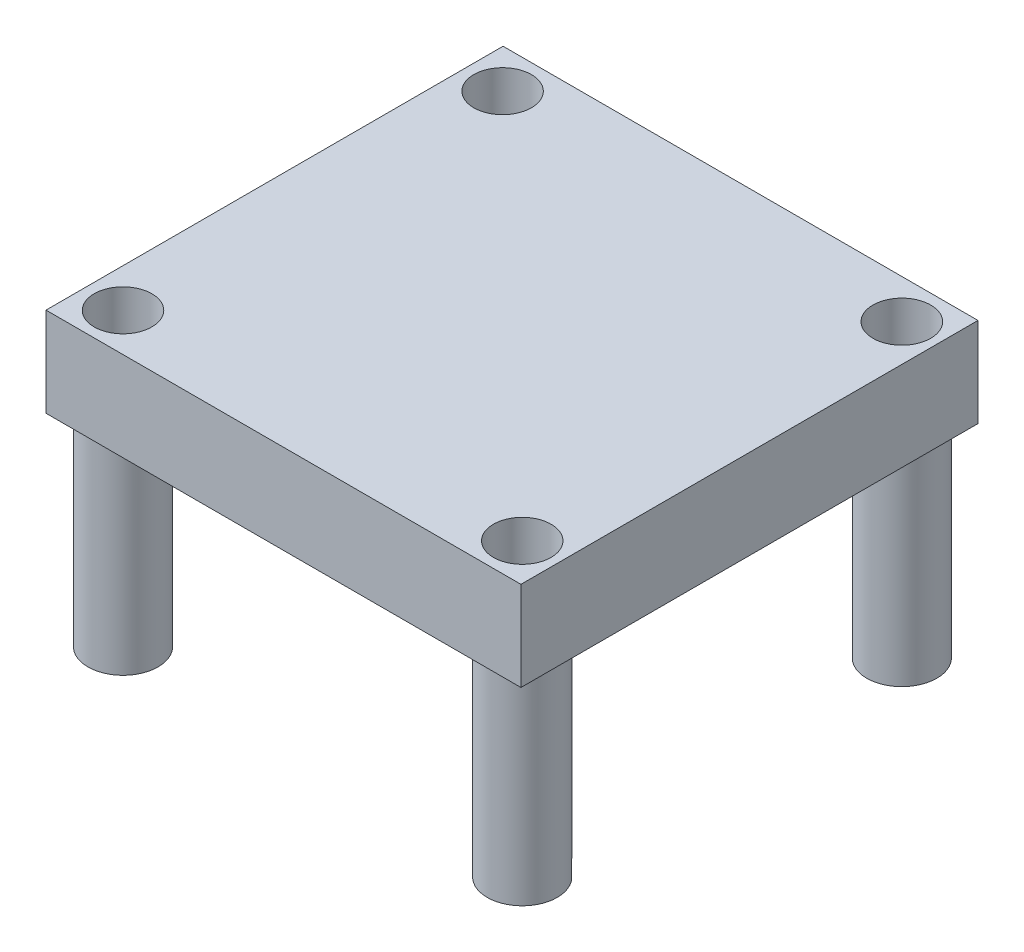
from build123d import *

# Parameters (mm, degrees)
SKETCH1_W               = 27.0002
SKETCH1_H               = 25.9842
BOSS_EXTRUDE1_DEPTH     = 5.08
SKETCH2_R               = 1.9939
SKETCH2_R_2             = 1.6383
BOSS_EXTRUDE2_DEPTH     = 11.4808
SKETCH3_R               = 1.641593419
SKETCH3_R_2             = 1.6383
CUT_EXTRUDE1_DEPTH      = 1
CUT_EXTRUDE1_DEPTH_BACK = 17.5608


with BuildPart() as part:
    # Sketch1 → Boss-Extrude1 (new body)
    with BuildSketch(Plane(origin=(0, 0, 0), x_dir=(1, 0, 0), z_dir=(0, 1, 0))):
        with Locations((2.217200719, -2.362930935)):
            Rectangle(SKETCH1_W, SKETCH1_H)
    extrude(amount=BOSS_EXTRUDE1_DEPTH)

    # Sketch2 → Boss-Extrude2 (add)
    with BuildSketch(Plane.XZ):
        with Locations((-9.082699611, 13.17672836)):
            Circle(SKETCH2_R)
        with Locations((-9.082699611, 13.17672836)):
            Circle(SKETCH2_R_2, mode=Mode.SUBTRACT)
        with Locations((13.612727851, 13.17672836)):
            Circle(SKETCH2_R)
        with Locations((13.612727851, 13.17672836)):
            Circle(SKETCH2_R_2, mode=Mode.SUBTRACT)
        with Locations((-9.082699611, -8.403053089)):
            Circle(SKETCH2_R)
        with Locations((-9.082699611, -8.403053089)):
            Circle(SKETCH2_R_2, mode=Mode.SUBTRACT)
        with Locations((13.612727851, -8.403053089)):
            Circle(SKETCH2_R)
        with Locations((13.612727851, -8.403053089)):
            Circle(SKETCH2_R_2, mode=Mode.SUBTRACT)
    extrude(amount=BOSS_EXTRUDE2_DEPTH)

    # Sketch3 → Cut-Extrude1 (cut, two sides)
    with BuildSketch(Plane(origin=(0, 5.08, 0), x_dir=(1, 0, 0), z_dir=(0, 1, 0))) as cut_extrude1_sk:
        with Locations((13.612727851, 8.403053089)):
            Circle(SKETCH3_R)
        with Locations((-9.082699611, 8.403053089)):
            Circle(SKETCH3_R_2)
        with Locations((13.612727851, -13.17672836)):
            Circle(SKETCH3_R_2)
        with Locations((-9.082699611, -13.17672836)):
            Circle(SKETCH3_R_2)
    extrude(amount=CUT_EXTRUDE1_DEPTH, mode=Mode.SUBTRACT)
    extrude(cut_extrude1_sk.sketch, amount=-CUT_EXTRUDE1_DEPTH_BACK, mode=Mode.SUBTRACT)


solid = part.part
